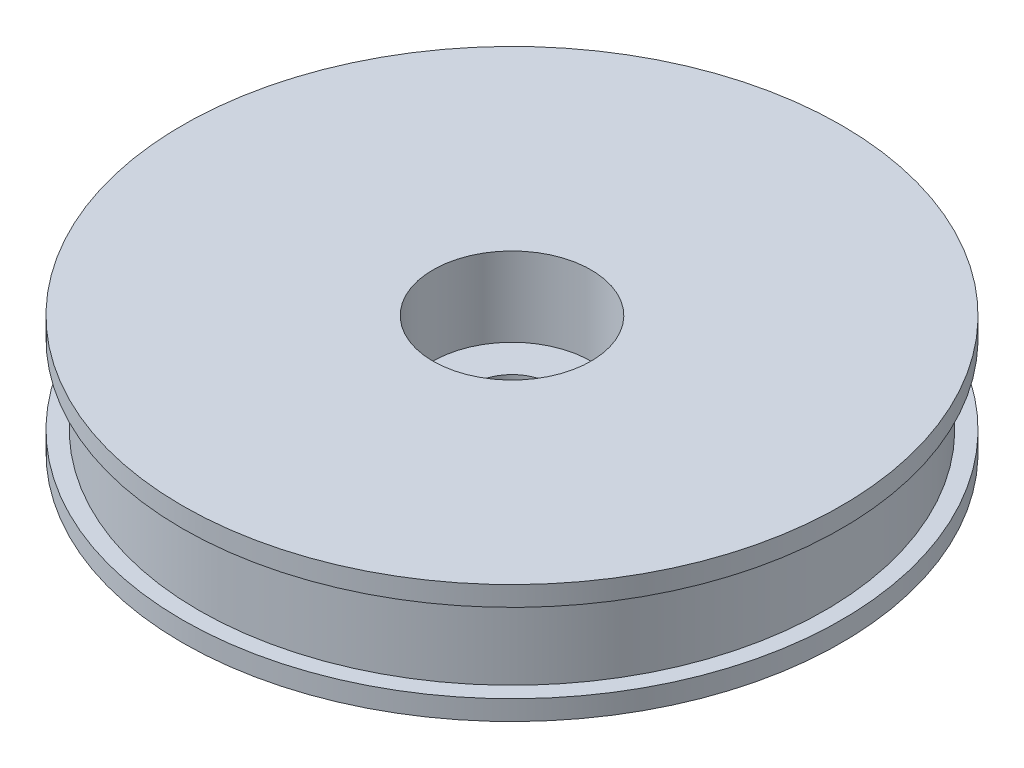
from build123d import *

# Parameters (mm, degrees)
SKETCH1_R           = 12.7
BOSS_EXTRUDE1_DEPTH = 0.762
SKETCH2_R           = 12.065
BOSS_EXTRUDE2_DEPTH = 3.048
SKETCH3_R           = 12.7
BOSS_EXTRUDE3_DEPTH = 0.762
SKETCH4_R           = 3.048
CUT_EXTRUDE1_DEPTH  = 3.048
SKETCH5_R           = 1.524
CUT_EXTRUDE2_DEPTH  = 2.524


with BuildPart() as part:
    # Sketch1 → Boss-Extrude1 (new body)
    with BuildSketch(Plane(origin=(0, 0, 0), x_dir=(1, 0, 0), z_dir=(0, 1, 0))):
        Circle(SKETCH1_R)
    extrude(amount=BOSS_EXTRUDE1_DEPTH)

    # Sketch2 → Boss-Extrude2 (add)
    with BuildSketch(Plane(origin=(0, 0.762, 0), x_dir=(1, 0, 0), z_dir=(0, 1, 0))):
        Circle(SKETCH2_R)
    extrude(amount=BOSS_EXTRUDE2_DEPTH)

    # Sketch3 → Boss-Extrude3 (add)
    with BuildSketch(Plane(origin=(0, 3.81, 0), x_dir=(1, 0, 0), z_dir=(0, 1, 0))):
        Circle(SKETCH3_R)
    extrude(amount=BOSS_EXTRUDE3_DEPTH)

    # Sketch4 → Cut-Extrude1 (cut)
    with BuildSketch(Plane(origin=(0, 4.572, 0), x_dir=(1, 0, 0), z_dir=(0, 1, 0))):
        Circle(SKETCH4_R)
    extrude(amount=-CUT_EXTRUDE1_DEPTH, mode=Mode.SUBTRACT)

    # Sketch5 → Cut-Extrude2 (cut, through all)
    with BuildSketch(Plane(origin=(0, 1.524, 0), x_dir=(1, 0, 0), z_dir=(0, 1, 0))):
        Circle(SKETCH5_R)
    extrude(amount=-CUT_EXTRUDE2_DEPTH, mode=Mode.SUBTRACT)


solid = part.part
